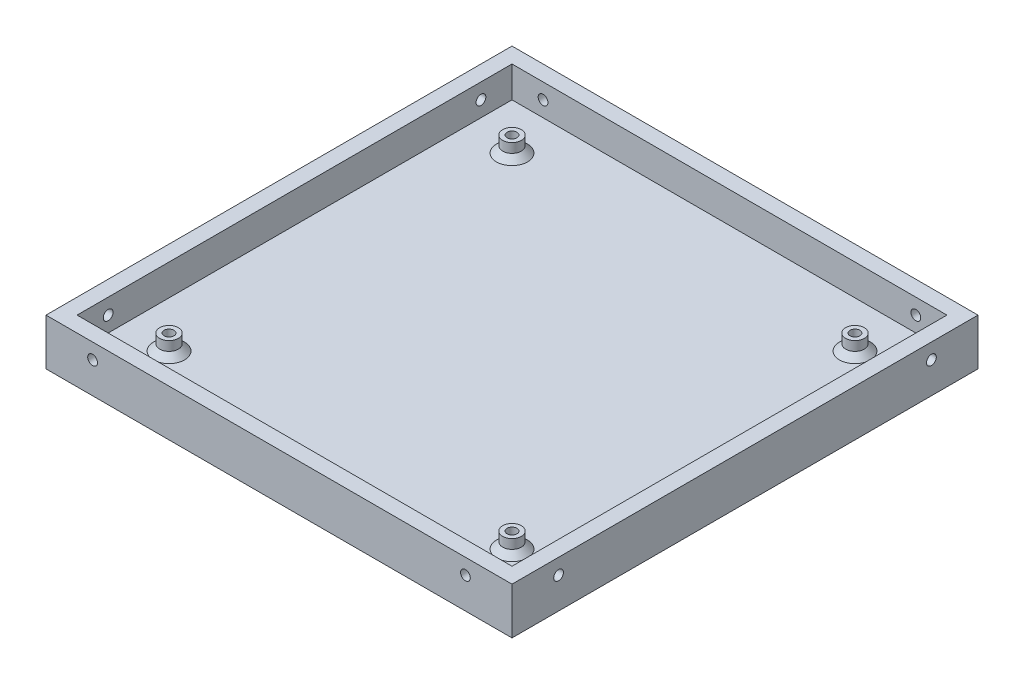
from build123d import *

# Parameters (mm, degrees)
SKETCH1_W           = 101.6
SKETCH1_H           = 101.6
BOSS_EXTRUDE1_DEPTH = 3.175
SKETCH2_W           = 101.6
SKETCH2_H           = 101.6
SKETCH2_W_2         = 88.9
SKETCH2_H_2         = 88.9
BOSS_EXTRUDE2_DEPTH = 6.35
SKETCH3_R           = 0.99949
CUT_EXTRUDE1_DEPTH  = 6.35
CIRPATTERN1_COUNT   = 4
SKETCH4_W           = 101.6
SKETCH4_H           = 101.6
SKETCH4_W_2         = 95.25
SKETCH4_H_2         = 95.25
CUT_EXTRUDE2_DEPTH  = 9.525
SKETCH5_R           = 1.905
SKETCH5_R_2         = 0.99949
BOSS_EXTRUDE3_DEPTH = 3.175
SKETCH6_R           = 0.99949
CUT_EXTRUDE3_DEPTH  = 7.35
CHAMFER1_SIZE       = 1.27
CHAMFER2_SIZE       = 1.27


with BuildPart() as part:
    # Sketch1 → Boss-Extrude1 (new body)
    with BuildSketch(Plane(origin=(0, 0, 0), x_dir=(1, 0, 0), z_dir=(0, 1, 0))):
        Rectangle(SKETCH1_W, SKETCH1_H)
    extrude(amount=BOSS_EXTRUDE1_DEPTH)

    # Sketch2 → Boss-Extrude2 (add)
    with BuildSketch(Plane(origin=(0, 3.175, 0), x_dir=(1, 0, 0), z_dir=(0, 1, 0))):
        Rectangle(SKETCH2_W, SKETCH2_H)
        Rectangle(SKETCH2_W_2, SKETCH2_H_2, mode=Mode.SUBTRACT)
    extrude(amount=BOSS_EXTRUDE2_DEPTH)

    # Sketch3 → Cut-Extrude1 (cut)
    with BuildSketch(Plane.XY.offset(50.8)):
        with Locations((-38.1, 6.35)):
            Circle(SKETCH3_R)
        with Locations((38.1, 6.35)):
            Circle(SKETCH3_R)
    cut_extrude1 = extrude(amount=-CUT_EXTRUDE1_DEPTH, mode=Mode.SUBTRACT)

    # CirPattern1: Cut-Extrude1 ×4 about axis
    cirpattern1_axis = Axis((0, 10.00125, 0), (0, -1, 0))
    for i in range(1, CIRPATTERN1_COUNT):
        add(cut_extrude1.rotate(cirpattern1_axis, i * 360 / CIRPATTERN1_COUNT), mode=Mode.SUBTRACT)

    # Sketch4 → Cut-Extrude2 (cut)
    with BuildSketch(Plane(origin=(0, 0, 0), x_dir=(1, 0, 0), z_dir=(0, 1, 0))):
        Rectangle(SKETCH4_W, SKETCH4_H)
        Rectangle(SKETCH4_W_2, SKETCH4_H_2, mode=Mode.SUBTRACT)
    extrude(amount=CUT_EXTRUDE2_DEPTH, mode=Mode.SUBTRACT)

    # Sketch5 → Boss-Extrude3 (add)
    with BuildSketch(Plane(origin=(0, 3.175, 0), x_dir=(1, 0, 0), z_dir=(0, 1, 0))):
        with Locations((-35.052, -35.052)):
            Circle(SKETCH5_R)
        with Locations((-35.052, -35.052)):
            Circle(SKETCH5_R_2, mode=Mode.SUBTRACT)
        with Locations((35.052, -35.052)):
            Circle(SKETCH5_R)
        with Locations((35.052, -35.052)):
            Circle(SKETCH5_R_2, mode=Mode.SUBTRACT)
        with Locations((35.052, 35.052)):
            Circle(SKETCH5_R)
        with Locations((35.052, 35.052)):
            Circle(SKETCH5_R_2, mode=Mode.SUBTRACT)
        with Locations((-35.052, 35.052)):
            Circle(SKETCH5_R)
        with Locations((-35.052, 35.052)):
            Circle(SKETCH5_R_2, mode=Mode.SUBTRACT)
    extrude(amount=BOSS_EXTRUDE3_DEPTH)

    # Sketch6 → Cut-Extrude3 (cut, through all)
    with BuildSketch(Plane(origin=(0, 6.35, 0), x_dir=(1, 0, 0), z_dir=(0, 1, 0))):
        with Locations((-35.052, 35.052)):
            Circle(SKETCH6_R)
        with Locations((35.052, 35.052)):
            Circle(SKETCH6_R)
        with Locations((35.052, -35.052)):
            Circle(SKETCH6_R)
        with Locations((-35.052, -35.052)):
            Circle(SKETCH6_R)
    extrude(amount=-CUT_EXTRUDE3_DEPTH, mode=Mode.SUBTRACT)

    # Chamfer1
    chamfer1_edges = [part.edges().sort_by_distance(p)[0] for p in [
        (-36.05149, 0, 35.052),
        (34.05251, 0, 35.052),
        (34.05251, 0, -35.052),
        (-36.05149, 0, -35.052),
    ]]
    chamfer(chamfer1_edges, length=CHAMFER1_SIZE)

    # Chamfer2
    chamfer2_edges = [part.edges().sort_by_distance(p)[0] for p in [
        (-36.957, 3.175, 35.052),
        (33.147, 3.175, 35.052),
        (33.147, 3.175, -35.052),
        (-36.957, 3.175, -35.052),
    ]]
    chamfer(chamfer2_edges, length=CHAMFER2_SIZE)


solid = part.part
